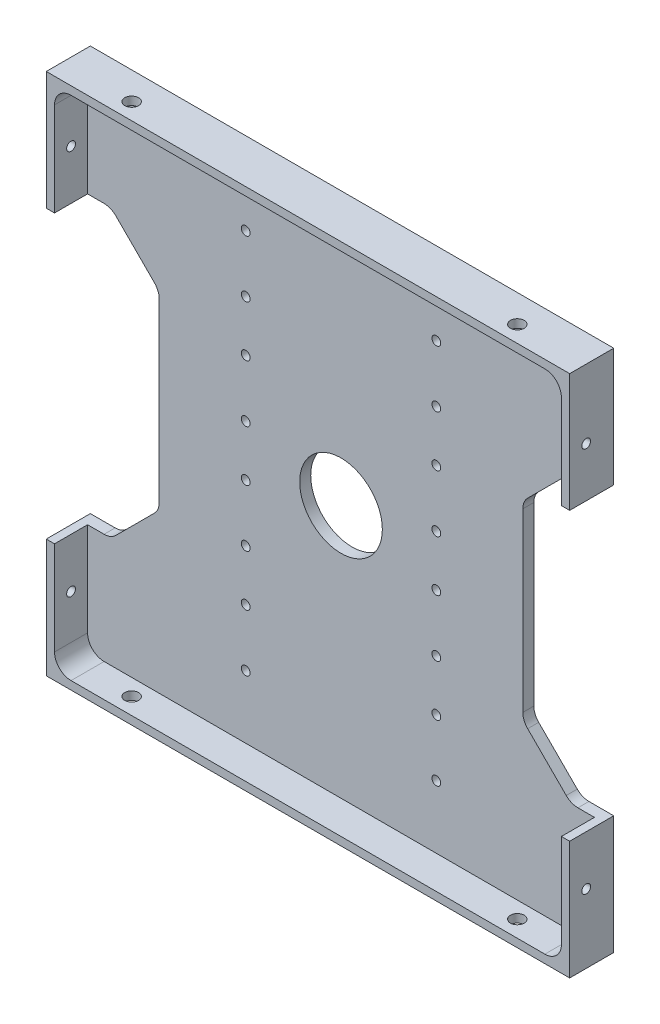
from build123d import *

# Parameters (mm, degrees)
SKETCH1_W                       = 96
SKETCH1_H                       = 96
BOSS_EXTRUDE1_DEPTH             = 8
SKETCH2_W                       = 92
SKETCH2_H                       = 92
COMPONENT_PLATFORM_DEPTH        = 6
CABLE_SLOTS_DEPTH               = 6
SKETCH4_R                       = 7.5
CENTER_MASS_CUT_DEPTH           = 6
INNER_CORNER_FILLETS_R          = 3
TAP_DRILL_FOR_M3X0_5_TAP4_D     = 2.5
TAP_DRILL_FOR_M3X0_5_TAP4_DEPTH = 2
TAP_DRILL_FOR_M2X0_4_TAP2_D     = 1.6
TAP_DRILL_FOR_M2X0_4_TAP1_D     = 1.6
TAP_DRILL_FOR_M2X0_4_TAP1_DEPTH = 2
CUT_EXTRUDE1_START              = -8
SKETCH28_OUTSIDE_W              = 125.2
SKETCH28_OUTSIDE_H              = 125.2
SKETCH28_OUTSIDE_W_2            = 95
SKETCH28_OUTSIDE_H_2            = 95
CUT_EXTRUDE1_DEPTH              = 8


with BuildPart() as part:
    # Sketch1 → Boss-Extrude1 (new body)
    with BuildSketch(Plane.XY):
        Rectangle(SKETCH1_W, SKETCH1_H)
    extrude(amount=BOSS_EXTRUDE1_DEPTH)

    # Sketch2 → Component Platform (cut)
    with BuildSketch(Plane.XY.offset(8)):
        Rectangle(SKETCH2_W, SKETCH2_H)
    extrude(amount=-COMPONENT_PLATFORM_DEPTH, mode=Mode.SUBTRACT)

    # Sketch3 → Cable Slots (cut, symmetric)
    with BuildSketch(Plane.XY.offset(2)):
        with BuildLine():
            Line((-40.878679656, -25.121320344), (-33.878679656, -18.121320344))
            ThreePointArc((-33.878679656, -18.121320344), (-33.228361402, -17.148050297), (-33, -16))
            Line((-33, -16), (-33, 16))
            ThreePointArc((-33, 16), (-33.228361402, 17.148050297), (-33.878679656, 18.121320344))
            Line((-33.878679656, 18.121320344), (-40.878679656, 25.121320344))
            ThreePointArc((-40.878679656, 25.121320344), (-41.851949703, 25.771638598), (-43, 26))
            Line((-43, 26), (-48, 26))
            Line((-48, 26), (-48, -26))
            Line((-48, -26), (-43, -26))
            ThreePointArc((-43, -26), (-41.851949703, -25.771638598), (-40.878679656, -25.121320344))
        make_face()
        with BuildLine():
            Line((48, -26), (48, 26))
            Line((48, 26), (43, 26))
            ThreePointArc((43, 26), (41.851949703, 25.771638598), (40.878679656, 25.121320344))
            Line((40.878679656, 25.121320344), (33.878679656, 18.121320344))
            ThreePointArc((33.878679656, 18.121320344), (33.228361402, 17.148050297), (33, 16))
            Line((33, 16), (33, -16))
            ThreePointArc((33, -16), (33.228361402, -17.148050297), (33.878679656, -18.121320344))
            Line((33.878679656, -18.121320344), (40.878679656, -25.121320344))
            ThreePointArc((40.878679656, -25.121320344), (41.851949703, -25.771638598), (43, -26))
            Line((43, -26), (48, -26))
        make_face()
    extrude(amount=CABLE_SLOTS_DEPTH, both=True, mode=Mode.SUBTRACT)

    # Sketch4 → Center Mass Cut (cut)
    with BuildSketch(Plane.XY.offset(2)):
        Circle(SKETCH4_R)
    extrude(amount=-CENTER_MASS_CUT_DEPTH, mode=Mode.SUBTRACT)

    # Inner Corner Fillets
    inner_corner_fillets_edges = [part.edges().sort_by_distance(p)[0] for p in [
        (-46, -46, 5),
        (-46, 46, 5),
        (46, 46, 5),
        (46, -46, 5),
    ]]
    fillet(inner_corner_fillets_edges, radius=INNER_CORNER_FILLETS_R)

    # Tap Drill for M3x0.5 Tap4
    with Locations(Plane(origin=(0, -48, 0), x_dir=(-1, 0, 0), z_dir=(0, -1, 0))):
        with Locations((35, -5), (-35, -5)):
            tap_drill_for_m3x0_5_tap4 = Hole(TAP_DRILL_FOR_M3X0_5_TAP4_D / 2, depth=TAP_DRILL_FOR_M3X0_5_TAP4_DEPTH)

    # Mirror2: Tap Drill for M3x0.5 Tap4 across plane
    add(tap_drill_for_m3x0_5_tap4.mirror(Plane(origin=(0, 0, 0), x_dir=(0, 0, 1), z_dir=(0, -1, 0))), mode=Mode.SUBTRACT)

    # Tap Drill for M2x0.4 Tap2 (through all)
    with Locations(Plane.XY.offset(2)):
        with Locations((-17.3, 34.575), (-17.3, 24.225), (-17.3, 14.975), (-17.3, 4.625), (17.3, 4.625), (17.3, 14.975), (17.3, 24.225), (17.3, 34.575), (17.3, -4.625), (17.3, -14.975), (17.3, -24.225), (17.3, -34.575), (-17.3, -4.625), (-17.3, -14.975), (-17.3, -24.225), (-17.3, -34.575)):
            Hole(TAP_DRILL_FOR_M2X0_4_TAP2_D / 2)

    # Tap Drill for M2x0.4 Tap1
    with Locations(Plane(origin=(48, 0, 0), x_dir=(0, 0, -1), z_dir=(1, 0, 0))):
        with Locations((-5, -35), (-5, 35)):
            tap_drill_for_m2x0_4_tap1 = Hole(TAP_DRILL_FOR_M2X0_4_TAP1_D / 2, depth=TAP_DRILL_FOR_M2X0_4_TAP1_DEPTH)

    # Mirror3: Tap Drill for M2x0.4 Tap1 across plane
    add(tap_drill_for_m2x0_4_tap1.mirror(Plane(origin=(0, 0, 0), x_dir=(0, 0, 1), z_dir=(1, 0, 0))), mode=Mode.SUBTRACT)

    # Sketch28 outside → Cut-Extrude1 (cut)
    with BuildSketch(Plane(origin=(0, 0, 0), x_dir=(-1, 0, 0), z_dir=(0, 0, -1)).offset(CUT_EXTRUDE1_START)):
        Rectangle(SKETCH28_OUTSIDE_W, SKETCH28_OUTSIDE_H)
        Rectangle(SKETCH28_OUTSIDE_W_2, SKETCH28_OUTSIDE_H_2, mode=Mode.SUBTRACT)
    extrude(amount=CUT_EXTRUDE1_DEPTH, mode=Mode.SUBTRACT)


solid = part.part
